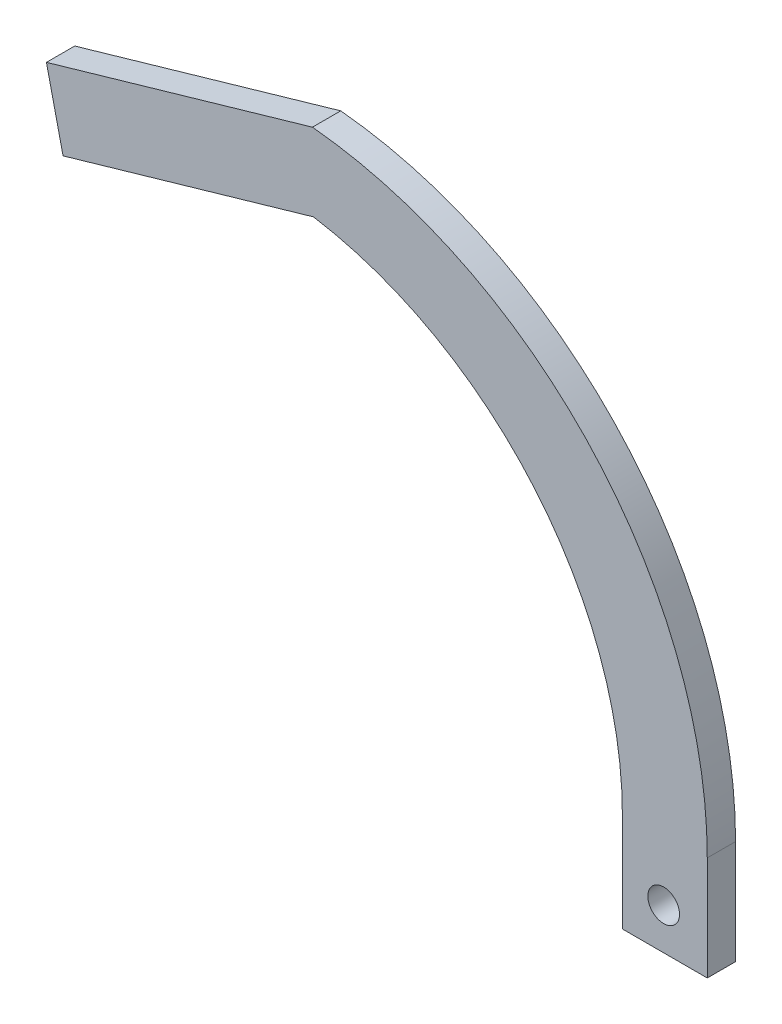
from build123d import *

# Parameters (mm, degrees)
BOSS_EXTRUDE1_DEPTH = 2.54
SKETCH2_R           = 2.8448
CUT_EXTRUDE1_DEPTH  = 5.08


with BuildPart() as part:
    # Sketch1 → Boss-Extrude1 (new body, symmetric)
    with BuildSketch(Plane.XY):
        with BuildLine():
            Line((-106.203198828, 123.8526304), (-153.956362537, 110.054547529))
            Line((-153.956362537, 110.054547529), (-150.972399128, 97.006641248))
            Line((-150.972399128, 97.006641248), (-106.007662429, 109.999019449))
            ThreePointArc((-106.007662429, 109.999019449), (-66.301425243, 87.590832017), (-50.567785145, 44.798721708))
            Line((-50.567785145, 44.798721708), (-50.567785145, 27.018721708))
            Line((-50.567785145, 27.018721708), (-35.327785145, 27.018721708))
            Line((-35.327785145, 27.018721708), (-35.327785145, 45.691652598))
            ThreePointArc((-35.327785145, 45.691652598), (-55.685055667, 98.44689574), (-106.203198828, 123.8526304))
        make_face()
    extrude(amount=BOSS_EXTRUDE1_DEPTH, both=True)

    # Sketch2 → Cut-Extrude1 (cut)
    with BuildSketch(Plane.XY.offset(2.54)):
        with Locations((-43.152202962, 34.412244361)):
            Circle(SKETCH2_R)
    extrude(amount=-CUT_EXTRUDE1_DEPTH, mode=Mode.SUBTRACT)


solid = part.part
